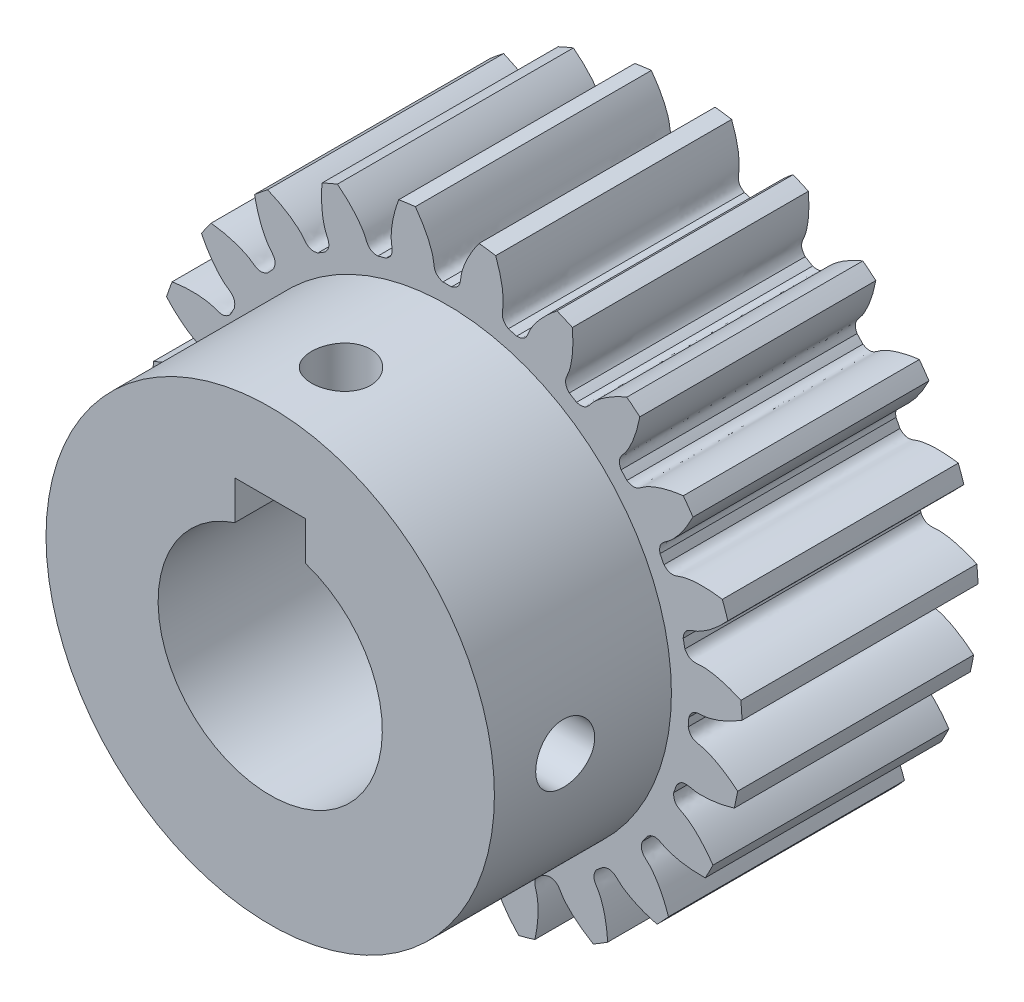
from build123d import *

# Parameters (mm, degrees)
SKETCH_1_R               = 25
EXTRUDE_1_DEPTH          = 20
CUT_EXTRUDE_1_DEPTH      = 41.620192023
PATTERN_CIRCULAR_1_COUNT = 23
SKETCH_4_R               = 19
EXTRUDE_2_DEPTH          = 15
SKETCH_5_R               = 9.5
CUT_EXTRUDE_2_DEPTH      = 50.739371114
SKETCH_6_W               = 6
SKETCH_6_H               = 12.3
CUT_EXTRUDE_3_DEPTH      = 50.739371114
HOLE_WIZARD_M6_1_REACH   = 63.516
HOLE_WIZARD_M6_1_BORE_R  = 2.5
PATTERN_CIRCULAR_2_COUNT = 2
PATTERN_CIRCULAR_2_ANGLE = 90


with BuildPart() as part:
    # 草图1 → 凸台-拉伸1 (new body)
    with BuildSketch(Plane.XY):
        Circle(SKETCH_1_R)
    extrude(amount=EXTRUDE_1_DEPTH)

    # 草图2 → 切除-拉伸1 (cut, through all)
    with BuildSketch(Plane.XY):
        with BuildLine():
            ThreePointArc((0.362755305, 20.496790202), (0, 20.5), (-0.362755305, 20.496790202))
            add(Edge.make_bspline(
                [(-0.362755305, 20.496790202), (-1.155466972, 20.733525948), (-1.087520616, 21.26767434), (-1.185859869, 21.794351938), (-1.198995845, 21.857849297), (-1.215324159, 21.929500041), (-1.235163177, 22.009201186), (-1.258844493, 22.096836763), (-1.286691262, 22.192281901), (-1.319024726, 22.295401644), (-1.356161833, 22.406051438), (-1.398415633, 22.524077112), (-1.446094819, 22.649315017), (-1.499503533, 22.781592128), (-1.5589411, 22.920726165), (-1.624701785, 23.066525721), (-1.697074541, 23.218790386), (-1.776342776, 23.377310889), (-1.862784108, 23.541869241), (-1.956670134, 23.71223888), (-2.058266195, 23.888184833), (-2.167831155, 24.069463867), (-2.28561717, 24.255824664), (-2.411869476, 24.447007991), (-2.546826167, 24.642746874), (-2.690717991, 24.842766783), (-2.843768139, 25.046785824), (-3.006192046, 25.254514926), (-3.178197192, 25.465658044), (-3.359982914, 25.679912362), (-3.551740212, 25.8969685), (-3.753651576, 26.116510729), (-3.965890802, 26.338217186), (-4.188622824, 26.561760101), (-4.422003548, 26.786806019), (-4.666179691, 27.013016034), (-4.921288623, 27.240046023), (-5.18745824, 27.467546885), (-5.464806735, 27.695164787), (-5.854182413, 28.001900287), (-6.156580907, 28.225592313), (-6.363361531, 28.372391104)],
                knots=[0, 0, 0, 0, 0.147386897, 0.152959532, 0.159389495, 0.166676786, 0.174821406, 0.183823355, 0.193682632, 0.204399237, 0.21597317, 0.228404432, 0.241693023, 0.255838942, 0.270842189, 0.286702764, 0.303420668, 0.320995901, 0.339428462, 0.358718351, 0.378865568, 0.399870114, 0.421731989, 0.444451192, 0.468027723, 0.492461582, 0.517752771, 0.543901287, 0.570907132, 0.598770305, 0.627490807, 0.657068637, 0.687503795, 0.718796282, 0.750946098, 0.783953241, 0.817817713, 0.852539514, 0.888118643, 0.9245551, 1, 1, 1, 1], degree=3))
            ThreePointArc((-6.363361531, 28.372391104), (0, 29.077223852), (6.363361531, 28.372391104))
            add(Edge.make_bspline(
                [(0.362755305, 20.496790202), (1.155466972, 20.733525948), (1.087520616, 21.26767434), (1.185859869, 21.794351938), (1.198995845, 21.857849297), (1.215324159, 21.929500041), (1.235163177, 22.009201186), (1.258844493, 22.096836763), (1.286691262, 22.192281901), (1.319024726, 22.295401644), (1.356161833, 22.406051438), (1.398415633, 22.524077112), (1.446094819, 22.649315017), (1.499503533, 22.781592128), (1.5589411, 22.920726165), (1.624701785, 23.066525721), (1.697074541, 23.218790386), (1.776342776, 23.377310889), (1.862784108, 23.541869241), (1.956670134, 23.71223888), (2.058266195, 23.888184833), (2.167831155, 24.069463867), (2.28561717, 24.255824664), (2.411869476, 24.447007991), (2.546826167, 24.642746874), (2.690717991, 24.842766783), (2.843768139, 25.046785824), (3.006192046, 25.254514926), (3.178197192, 25.465658044), (3.359982914, 25.679912362), (3.551740212, 25.8969685), (3.753651576, 26.116510729), (3.965890802, 26.338217186), (4.188622824, 26.561760101), (4.422003548, 26.786806019), (4.666179691, 27.013016034), (4.921288623, 27.240046023), (5.18745824, 27.467546885), (5.464806735, 27.695164787), (5.854182413, 28.001900287), (6.156580907, 28.225592313), (6.363361531, 28.372391104)],
                knots=[0, 0, 0, 0, 0.147386897, 0.152959532, 0.159389495, 0.166676786, 0.174821406, 0.183823355, 0.193682632, 0.204399237, 0.21597317, 0.228404432, 0.241693023, 0.255838942, 0.270842189, 0.286702764, 0.303420668, 0.320995901, 0.339428462, 0.358718351, 0.378865568, 0.399870114, 0.421731989, 0.444451192, 0.468027723, 0.492461582, 0.517752771, 0.543901287, 0.570907132, 0.598770305, 0.627490807, 0.657068637, 0.687503795, 0.718796282, 0.750946098, 0.783953241, 0.817817713, 0.852539514, 0.888118643, 0.9245551, 1, 1, 1, 1], degree=3))
        make_face()
    cut_extrude_1 = extrude(amount=CUT_EXTRUDE_1_DEPTH, mode=Mode.SUBTRACT)

    # 阵列(圆周)1: 切除-拉伸1 ×23 about axis
    pattern_circular_1_axis = Axis((0, 0, 20), (0, 0, -1))
    for i in range(1, PATTERN_CIRCULAR_1_COUNT):
        add(cut_extrude_1.rotate(pattern_circular_1_axis, i * 360 / PATTERN_CIRCULAR_1_COUNT), mode=Mode.SUBTRACT)

    # 草图4 → 凸台-拉伸2 (add)
    with BuildSketch(Plane.XY.offset(20)):
        Circle(SKETCH_4_R)
    extrude(amount=EXTRUDE_2_DEPTH)

    # 草图5 → 切除-拉伸2 (cut, through all)
    with BuildSketch(Plane.XY.offset(35)):
        Circle(SKETCH_5_R)
    extrude(amount=-CUT_EXTRUDE_2_DEPTH, mode=Mode.SUBTRACT)

    # 草图6 → 切除-拉伸3 (cut, through all)
    with BuildSketch(Plane.XY.offset(35)):
        with Locations((0, 6.15)):
            Rectangle(SKETCH_6_W, SKETCH_6_H)
    extrude(amount=-CUT_EXTRUDE_3_DEPTH, mode=Mode.SUBTRACT)

    # M6 螺纹孔1 bore → M6 螺纹孔1 (cut, up to next)
    with BuildSketch(Plane(origin=(19, 0, 0), x_dir=(0, 0, -1), z_dir=(1, 0, 0)), mode=Mode.PRIVATE) as hole_wizard_m6_1_sk1:
        with Locations((-29, 0)):
            Circle(HOLE_WIZARD_M6_1_BORE_R)
    hole_wizard_m6_1_tool1 = extrude(hole_wizard_m6_1_sk1.sketch, amount=-HOLE_WIZARD_M6_1_REACH, mode=Mode.PRIVATE) & part.part
    hole_wizard_m6_1 = hole_wizard_m6_1_tool1.solids().sort_by_distance((19, 0, 29))[0]
    add(hole_wizard_m6_1, mode=Mode.SUBTRACT)

    # 阵列(圆周)2: M6 螺纹孔1 ×2 about axis
    pattern_circular_2_axis = Axis((0, 0, 35), (0, 0, 1))
    for i in range(1, PATTERN_CIRCULAR_2_COUNT):
        add(hole_wizard_m6_1.rotate(pattern_circular_2_axis, i * PATTERN_CIRCULAR_2_ANGLE / (PATTERN_CIRCULAR_2_COUNT - 1)), mode=Mode.SUBTRACT)


solid = part.part
